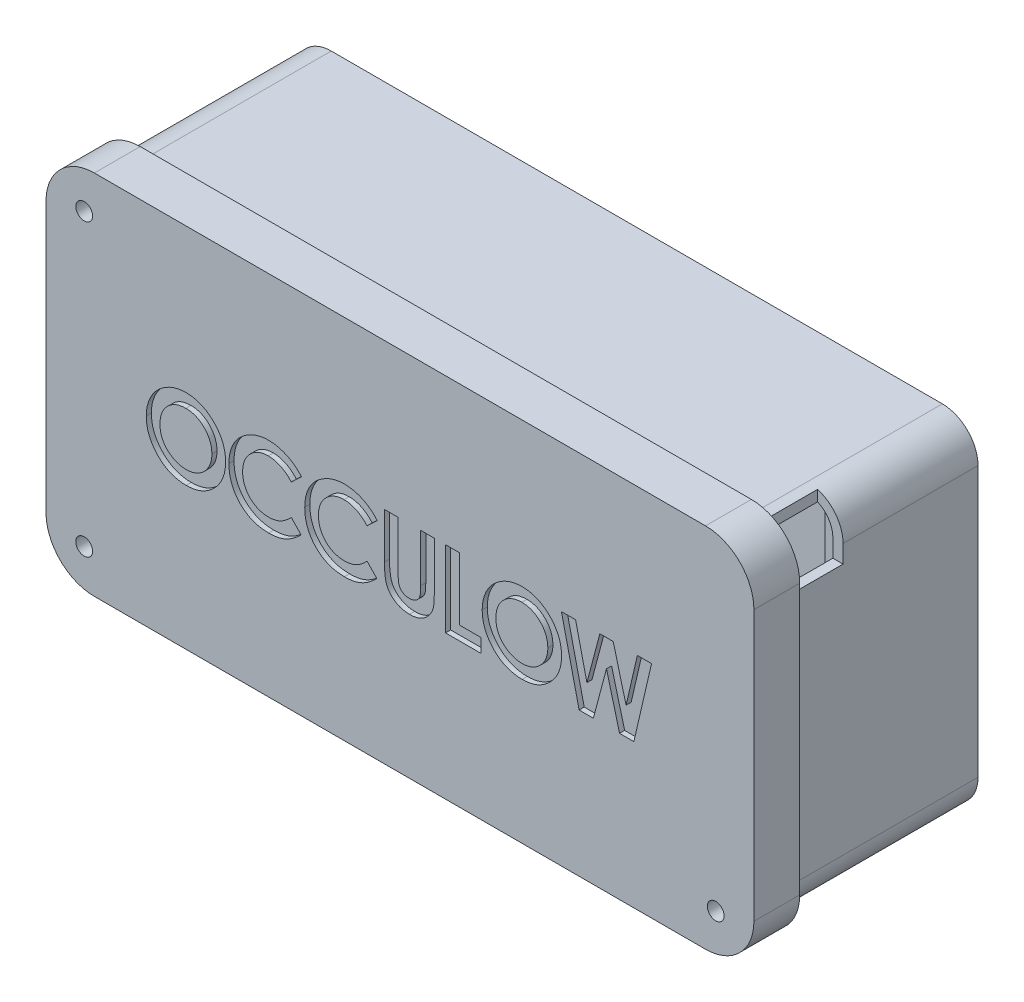
from build123d import *

# Parameters (mm, degrees)
SKETCH1_W            = 130
SKETCH1_H            = 40
SKETCH1_R            = 5.5
SKETCH1_W_2          = 10
SKETCH1_H_2          = 7
BOSS_EXTRUDE1_DEPTH  = 2
SKETCH2_W            = 130
SKETCH2_H            = 65
SKETCH2_R            = 1
BOSS_EXTRUDE2_DEPTH  = 3.5
SKETCH4_R            = 3.5
SKETCH4_R_2          = 1
BOSS_EXTRUDE3_DEPTH  = 2.5
SKETCH5_W            = 43.5
SKETCH5_H            = 65
BOSS_EXTRUDE4_DEPTH  = 2
SKETCH6_W            = 6.5
SKETCH6_H            = 6.5
BOSS_EXTRUDE5_DEPTH  = 40
SKETCH7_W            = 43.5
SKETCH7_H            = 65
BOSS_EXTRUDE6_DEPTH  = 2
SKETCH8_W            = 134
SKETCH8_H            = 43.5
BOSS_EXTRUDE7_DEPTH  = 2
SKETCH12_W           = 9.5
SKETCH12_H           = 63
BOSS_EXTRUDE10_DEPTH = 15
SKETCH9_W            = 5
SKETCH9_H            = 10.5
CUT_EXTRUDE1_DEPTH   = 17
BOSS_EXTRUDE8_DEPTH  = 18
BOSS_EXTRUDE9_DEPTH  = 40
SKETCH13_R           = 1
CUT_EXTRUDE2_DEPTH   = 25
FILLET1_R            = 5
FILLET2_R            = 7
FILLET3_R            = 1
BOSS_EXTRUDE11_DEPTH = 6
SKETCH15_R           = 1.65
BOSS_EXTRUDE12_DEPTH = 3
CUT_EXTRUDE3_DEPTH   = 1


with BuildPart() as part:
    # Sketch1 → Boss-Extrude1 (new body)
    with BuildSketch(Plane(origin=(0, 0, 0), x_dir=(1, 0, 0), z_dir=(0, 1, 0))):
        with Locations((0, 7.5)):
            Rectangle(SKETCH1_W, SKETCH1_H)
        with Locations((0, 15)):
            Circle(SKETCH1_R, mode=Mode.SUBTRACT)
        Rectangle(SKETCH1_W_2, SKETCH1_H_2, mode=Mode.SUBTRACT)
    extrude(amount=-BOSS_EXTRUDE1_DEPTH)

    # Sketch2 → Boss-Extrude2 (add)
    with BuildSketch(Plane(origin=(0, 0, -27.5), x_dir=(-1, 0, 0), z_dir=(0, 0, -1))):
        with Locations((0, 30.5)):
            Rectangle(SKETCH2_W, SKETCH2_H)
        with Locations((-15, 56)):
            Circle(SKETCH2_R, mode=Mode.SUBTRACT)
        with Locations((-45, 56)):
            Circle(SKETCH2_R, mode=Mode.SUBTRACT)
        with Locations((-45, 14)):
            Circle(SKETCH2_R, mode=Mode.SUBTRACT)
        with Locations((-15, 14)):
            Circle(SKETCH2_R, mode=Mode.SUBTRACT)
        with Locations((35, 45.5)):
            Circle(SKETCH2_R, mode=Mode.SUBTRACT)
        with Locations((35, 15.5)):
            Circle(SKETCH2_R, mode=Mode.SUBTRACT)
    extrude(amount=BOSS_EXTRUDE2_DEPTH)

    # Sketch4 → Boss-Extrude3 (add)
    with BuildSketch(Plane.XY.offset(-27.5)):
        with Locations((15, 56)):
            Circle(SKETCH4_R)
        with Locations((15, 56)):
            Circle(SKETCH4_R_2, mode=Mode.SUBTRACT)
        with Locations((45, 56)):
            Circle(SKETCH4_R)
        with Locations((45, 56)):
            Circle(SKETCH4_R_2, mode=Mode.SUBTRACT)
        with Locations((15, 14)):
            Circle(SKETCH4_R)
        with Locations((15, 14)):
            Circle(SKETCH4_R_2, mode=Mode.SUBTRACT)
        with Locations((45, 14)):
            Circle(SKETCH4_R)
        with Locations((45, 14)):
            Circle(SKETCH4_R_2, mode=Mode.SUBTRACT)
    extrude(amount=BOSS_EXTRUDE3_DEPTH)

    # Sketch5 → Boss-Extrude4 (add)
    with BuildSketch(Plane(origin=(65, 0, 0), x_dir=(0, 0, -1), z_dir=(1, 0, 0))):
        with Locations((9.25, 30.5)):
            Rectangle(SKETCH5_W, SKETCH5_H)
    extrude(amount=BOSS_EXTRUDE4_DEPTH)

    # Sketch6 → Boss-Extrude5 (add)
    with BuildSketch(Plane.XY.offset(12.5)):
        Polygon((55.5, 9), (55.5, 0), (65, 0), (65, 12), (58.5, 12), (58.5, 14), (55.5, 14), align=None)
        with Locations((-61.75, 59.75)):
            Rectangle(SKETCH6_W, SKETCH6_H)
        with Locations((-61.75, 3.25)):
            Rectangle(SKETCH6_W, SKETCH6_H)
    extrude(amount=-BOSS_EXTRUDE5_DEPTH)

    # Sketch7 → Boss-Extrude6 (add)
    with BuildSketch(Plane.ZY.offset(65)):
        with Locations((-9.25, 30.5)):
            Rectangle(SKETCH7_W, SKETCH7_H)
    extrude(amount=BOSS_EXTRUDE6_DEPTH)

    # Sketch8 → Boss-Extrude7 (add)
    with BuildSketch(Plane(origin=(0, 63, 0), x_dir=(1, 0, 0), z_dir=(0, 1, 0))):
        with Locations((0, 9.25)):
            Rectangle(SKETCH8_W, SKETCH8_H)
    extrude(amount=BOSS_EXTRUDE7_DEPTH)

    # Sketch12 → Boss-Extrude10 (add)
    with BuildSketch(Plane.XY.offset(-27.5)):
        with Locations((60.25, 31.5)):
            Rectangle(SKETCH12_W, SKETCH12_H)
    extrude(amount=BOSS_EXTRUDE10_DEPTH)

    # Sketch9 → Cut-Extrude1 (cut)
    with BuildSketch(Plane.XY.offset(12.5)):
        with Locations((64.5, 59.75)):
            Rectangle(SKETCH9_W, SKETCH9_H)
    extrude(amount=-CUT_EXTRUDE1_DEPTH, mode=Mode.SUBTRACT)

    # Sketch10 → Boss-Extrude8 (add)
    with BuildSketch(Plane.XY.offset(-27.5)):
        Polygon((-14.75, 0), (-6.75, 8), (-4.7, 5), (-6.75, 5), (-6.75, 0), align=None)
        Polygon((4.7, 5), (6.75, 5), (6.75, 0), (14.75, 0), (6.75, 8), align=None)
    extrude(amount=BOSS_EXTRUDE8_DEPTH)

    # Sketch11 → Boss-Extrude9 (add)
    with BuildSketch(Plane.XY.offset(-27.5)):
        Polygon((-21, 0), (-21, 5), (-18.25, 5), (-21, 8), (-29, 0), align=None)
        Polygon((29, 0), (21, 0), (21, 5), (18.25, 5), (21, 8), align=None)
    extrude(amount=BOSS_EXTRUDE9_DEPTH)

    # Sketch13 → Cut-Extrude2 (cut)
    with BuildSketch(Plane.XY.offset(12.5)):
        with Locations((-62, 60)):
            Circle(SKETCH13_R)
        with Locations((-62, 3)):
            Circle(SKETCH13_R)
        with Locations((62, 3)):
            Circle(SKETCH13_R)
    extrude(amount=-CUT_EXTRUDE2_DEPTH, mode=Mode.SUBTRACT)

    # Fillet1
    fillet1_edges = [part.edges().sort_by_distance(p)[0] for p in [
        (65, 63, -8.5),
        (-65, 56.5, -7.5),
        (-58.5, 63, -7.5),
        (55.5, 0, -7.5),
        (-58.5, 0, -7.5),
        (-65, 6.5, -7.5),
        (55.5, 63, -20),
        (14.75, 0, -18.5),
        (-14.75, 0, -18.5),
        (29, 0, -7.5),
        (-29, 0, -7.5),
    ]]
    fillet(fillet1_edges, radius=FILLET1_R)

    # Fillet2
    fillet2_edges = [part.edges().sort_by_distance(p)[0] for p in [
        (67, 65, -17.75),
        (67, -2, -9.25),
        (-67, 65, -9.25),
        (-58.5, 56.5, -7.5),
        (-58.5, 6.5, -7.5),
        (-67, -2, -9.25),
    ]]
    fillet(fillet2_edges, radius=FILLET2_R)

    # Fillet3
    fillet3_edges = [part.edges().sort_by_distance(p)[0] for p in [
        (-6.75, 8, -18.5),
        (6.75, 8, -18.5),
        (-21, 8, -7.5),
        (21, 8, -7.5),
    ]]
    fillet(fillet3_edges, radius=FILLET3_R)


with BuildPart() as body_2:
    # Sketch14 → Boss-Extrude11 (new body)
    with BuildSketch(Plane.XY.offset(12.5)):
        with BuildLine():
            Line((60, 67.5), (-60, 67.5))
            ThreePointArc((-60, 67.5), (-66.717514421, 64.717514421), (-69.5, 58))
            Line((-69.5, 58), (-69.5, 5))
            ThreePointArc((-69.5, 5), (-66.717514421, -1.717514421), (-60, -4.5))
            Line((-60, -4.5), (60, -4.5))
            ThreePointArc((60, -4.5), (66.717514421, -1.717514421), (69.5, 5))
            Line((69.5, 5), (69.5, 58))
            ThreePointArc((69.5, 58), (66.717514421, 64.717514421), (60, 67.5))
        make_face()
        with BuildLine():
            Line((60, 65.5), (-60, 65.5))
            ThreePointArc((-60, 65.5), (-65.303300859, 63.303300859), (-67.5, 58))
            Line((-67.5, 58), (-67.5, 5))
            ThreePointArc((-67.5, 5), (-65.303300859, -0.303300859), (-60, -2.5))
            Line((-60, -2.5), (60, -2.5))
            ThreePointArc((60, -2.5), (65.303300859, -0.303300859), (67.5, 5))
            Line((67.5, 5), (67.5, 58))
            ThreePointArc((67.5, 58), (65.303300859, 63.303300859), (60, 65.5))
        make_face(mode=Mode.SUBTRACT)
    extrude(amount=-BOSS_EXTRUDE11_DEPTH)

    # Sketch15 → Boss-Extrude12 (add)
    with BuildSketch(Plane.XY.offset(12.5)):
        with BuildLine():
            Line((60, 67.5), (-60, 67.5))
            ThreePointArc((-60, 67.5), (-66.717514421, 64.717514421), (-69.5, 58))
            Line((-69.5, 58), (-69.5, 5))
            ThreePointArc((-69.5, 5), (-66.717514421, -1.717514421), (-60, -4.5))
            Line((-60, -4.5), (60, -4.5))
            ThreePointArc((60, -4.5), (66.717514421, -1.717514421), (69.5, 5))
            Line((69.5, 5), (69.5, 58))
            ThreePointArc((69.5, 58), (66.717514421, 64.717514421), (60, 67.5))
        make_face()
        with Locations((62, 3)):
            Circle(SKETCH15_R, mode=Mode.SUBTRACT)
        with Locations((-62, 3)):
            Circle(SKETCH15_R, mode=Mode.SUBTRACT)
        with Locations((-62, 60)):
            Circle(SKETCH15_R, mode=Mode.SUBTRACT)
    extrude(amount=BOSS_EXTRUDE12_DEPTH)

    # Sketch16 → Cut-Extrude3 (cut)
    with BuildSketch(Plane.XY.offset(15.5)):
        with BuildLine():
            add(Edge.make_bspline(
                [(-41.995066722, 39.162258162), (-41.734273339, 39.155505754), (-41.219408132, 39.142174972), (-40.462227207, 39.031052498), (-39.732543384, 38.849994357), (-39.030686623, 38.598310446), (-38.358414294, 38.269183885), (-37.713355065, 37.871945627), (-37.09781951, 37.39909804), (-36.518115143, 36.861671876), (-35.982363756, 36.27724439), (-35.518134866, 35.648004298), (-35.122257499, 34.990255843), (-34.794153279, 34.302236569), (-34.544240845, 33.579181614), (-34.368866952, 32.824777604), (-34.256197915, 32.039239158), (-34.243239243, 31.504394547), (-34.236653261, 31.232570662)],
                knots=[0, 0, 0, 0, 0.000782082, 0.001544006, 0.00229027, 0.003034499, 0.003776315, 0.004531831, 0.0053035, 0.006100907, 0.006900716, 0.007678376, 0.008442596, 0.009200665, 0.009960888, 0.010732725, 0.011521429, 0.01233653, 0.01233653, 0.01233653, 0.01233653], degree=3))
            add(Edge.make_bspline(
                [(-34.236653261, 31.232570662), (-34.243667046, 30.963809604), (-34.257487936, 30.434207317), (-34.364267309, 29.655907918), (-34.54259452, 28.909585146), (-34.788268243, 28.193549683), (-35.110421893, 27.51126976), (-35.49857922, 26.858389113), (-35.962982957, 26.240966633), (-36.486694477, 25.65933365), (-37.06325541, 25.131376913), (-37.673924967, 24.66611595), (-38.315883451, 24.271871368), (-38.988191242, 23.94882375), (-39.69229007, 23.69811839), (-40.426440725, 23.521227542), (-41.190597779, 23.413727402), (-41.710261633, 23.399996789), (-41.974033069, 23.393027393)],
                knots=[0, 0, 0, 0, 0.000806095, 0.001588437, 0.002351504, 0.003105064, 0.003855135, 0.004611112, 0.005379744, 0.006169048, 0.006955929, 0.007721565, 0.008468815, 0.009212029, 0.009955244, 0.010706626, 0.011474083, 0.012265169, 0.012265169, 0.012265169, 0.012265169], degree=3))
            add(Edge.make_bspline(
                [(-41.974033069, 23.393027393), (-42.249906363, 23.399279285), (-42.791959677, 23.411563398), (-43.585257129, 23.52837971), (-44.345304634, 23.704345882), (-45.065717357, 23.966965953), (-45.753832085, 24.295263126), (-46.404593036, 24.699580777), (-47.017781512, 25.179250739), (-47.589880165, 25.721988488), (-48.10820293, 26.315862626), (-48.565724439, 26.943237988), (-48.951653981, 27.599321979), (-49.266005677, 28.284421659), (-49.513827926, 28.994279302), (-49.688638366, 29.733218144), (-49.791903064, 30.499465943), (-49.806287236, 31.019916765), (-49.813576338, 31.283652393)],
                knots=[0, 0, 0, 0, 0.000827108, 0.001625155, 0.002400611, 0.003163838, 0.003920489, 0.004684278, 0.005457238, 0.006252167, 0.007046466, 0.007818795, 0.008578411, 0.00932595, 0.010076671, 0.010830273, 0.011600302, 0.012391388, 0.012391388, 0.012391388, 0.012391388], degree=3))
            add(Edge.make_bspline(
                [(-49.813576338, 31.283652393), (-49.811288598, 31.461079916), (-49.806742086, 31.813688324), (-49.751974561, 32.336235986), (-49.673125072, 32.848584218), (-49.556510419, 33.348690282), (-49.414853421, 33.840082193), (-49.231316769, 34.318185954), (-49.02240239, 34.788109027), (-48.778305608, 35.244301033), (-48.506893588, 35.682564623), (-48.21075891, 36.100832433), (-47.889156948, 36.494046992), (-47.543123686, 36.864792345), (-47.171466649, 37.210631556), (-46.779074601, 37.53646046), (-46.358337419, 37.833623884), (-45.918463723, 38.109379149), (-45.461933417, 38.358739854), (-44.990604994, 38.570988228), (-44.514188752, 38.756341118), (-44.026320412, 38.902629814), (-43.53222835, 39.021780427), (-43.026634194, 39.100576772), (-42.5141057, 39.15534278), (-42.168490309, 39.159947564), (-41.995066722, 39.162258162)],
                knots=[0, 0, 0, 0, 0.000532063, 0.001057389, 0.001574609, 0.002086309, 0.002596888, 0.003107537, 0.003621315, 0.004138849, 0.004658342, 0.005166928, 0.005675176, 0.006181145, 0.006687113, 0.007197268, 0.007710043, 0.008231124, 0.00875415, 0.009269166, 0.009780884, 0.010286567, 0.010796022, 0.011304341, 0.011820696, 0.012340744, 0.012340744, 0.012340744, 0.012340744], degree=3))
        make_face()
        with BuildLine():
            add(Edge.make_bspline(
                [(-42.03713403, 36.46995047), (-42.212647943, 36.465241037), (-42.559042172, 36.455946502), (-43.067139422, 36.385134718), (-43.554930726, 36.272040248), (-44.019712063, 36.108224291), (-44.463497836, 35.899728155), (-44.88707474, 35.64728035), (-45.28457711, 35.342203265), (-45.661305257, 35.000875129), (-46.001617146, 34.620557143), (-46.302293436, 34.212981742), (-46.553911061, 33.778829569), (-46.764642398, 33.322133795), (-46.923276391, 32.837758998), (-47.036266628, 32.329499337), (-47.107672239, 31.796479056), (-47.116673006, 31.433119824), (-47.121268646, 31.2475947)],
                knots=[0, 0, 0, 0, 0.000526391, 0.001038884, 0.001535951, 0.002026315, 0.002514261, 0.003004845, 0.003502447, 0.004015038, 0.00452784, 0.005030874, 0.005531803, 0.006030656, 0.006537115, 0.007057606, 0.007590949, 0.008147358, 0.008147358, 0.008147358, 0.008147358], degree=3))
            add(Edge.make_bspline(
                [(-47.121268646, 31.2475947), (-47.115175528, 31.04199113), (-47.103234029, 30.6390422), (-47.019212183, 30.051231156), (-46.875459168, 29.496101966), (-46.66788261, 28.976369682), (-46.41043322, 28.486263068), (-46.090721938, 28.031789076), (-45.713926572, 27.610226529), (-45.423646474, 27.364100755), (-45.276316722, 27.239181239)],
                knots=[0, 0, 0, 0, 0.000616718, 0.001208665, 0.001777146, 0.002332897, 0.002884015, 0.003434191, 0.003995905, 0.004574828, 0.004574828, 0.004574828, 0.004574828], degree=3))
            add(Edge.make_bspline(
                [(-45.276316722, 27.239181239), (-45.155625529, 27.146895498), (-44.916962335, 26.964403231), (-44.536003915, 26.730501953), (-44.143691758, 26.530025224), (-43.737065375, 26.368042399), (-43.316983541, 26.240629432), (-42.883503861, 26.151404226), (-42.43724054, 26.095407692), (-42.135456368, 26.088715046), (-41.983047492, 26.085335085)],
                knots=[0, 0, 0, 0, 0.000455543, 0.000900823, 0.001338907, 0.001775804, 0.002212123, 0.002654105, 0.003102094, 0.00355918, 0.00355918, 0.00355918, 0.00355918], degree=3))
            add(Edge.make_bspline(
                [(-41.983047492, 26.085335085), (-41.810551545, 26.090084448), (-41.471160345, 26.099428969), (-40.9725216, 26.169369022), (-40.494810537, 26.287732844), (-40.035061486, 26.450111749), (-39.594600157, 26.661225735), (-39.175579205, 26.921503679), (-38.777263973, 27.227749703), (-38.401015773, 27.573560225), (-38.057107133, 27.955376401), (-37.757058292, 28.365125768), (-37.497440484, 28.79378032), (-37.291091307, 29.247407014), (-37.126190044, 29.721723826), (-37.014559704, 30.218831402), (-36.942550877, 30.736680476), (-36.933547575, 31.089095072), (-36.928960953, 31.268628354)],
                knots=[0, 0, 0, 0, 0.000517386, 0.001017973, 0.001506981, 0.001991678, 0.002478197, 0.002969343, 0.003468766, 0.003983387, 0.004500432, 0.005007666, 0.00550495, 0.006001071, 0.006499951, 0.007008723, 0.007527172, 0.008065569, 0.008065569, 0.008065569, 0.008065569], degree=3))
            add(Edge.make_bspline(
                [(-36.928960953, 31.268628354), (-36.933706273, 31.447129271), (-36.94304671, 31.798481102), (-37.013109861, 32.314998791), (-37.13072305, 32.809911782), (-37.293589562, 33.284028323), (-37.501561474, 33.737813223), (-37.75873984, 34.169670706), (-38.064222255, 34.579183272), (-38.41097806, 34.963560249), (-38.788400441, 35.316778069), (-39.193601078, 35.623306929), (-39.615242004, 35.889670762), (-40.062997718, 36.098329433), (-40.527707512, 36.264567353), (-41.012207072, 36.386987343), (-41.518331467, 36.455449046), (-41.862658359, 36.465073575), (-42.03713403, 36.46995047)],
                knots=[0, 0, 0, 0, 0.000535396, 0.001053845, 0.001560375, 0.002059255, 0.002555376, 0.003055241, 0.003564261, 0.00408555, 0.004606457, 0.00511248, 0.005607763, 0.006099708, 0.006591074, 0.00708664, 0.007596156, 0.008119545, 0.008119545, 0.008119545, 0.008119545], degree=3))
        make_face(mode=Mode.SUBTRACT)
        with BuildLine():
            Line((-19.352037876, 36.175479316), (-21.32619653, 34.288460085))
            add(Edge.make_bspline(
                [(-21.32619653, 34.288460085), (-21.49366075, 34.461618369), (-21.820770837, 34.799850747), (-22.347868287, 35.247640608), (-22.896030443, 35.620812869), (-23.454593904, 35.935096171), (-24.033605609, 36.172873888), (-24.626370605, 36.346146516), (-25.23667387, 36.451784288), (-25.649703646, 36.463871118), (-25.85744653, 36.46995047)],
                knots=[0, 0, 0, 0, 0.000722405, 0.001411083, 0.002070342, 0.002709208, 0.003330281, 0.003943623, 0.004559132, 0.005182004, 0.005182004, 0.005182004, 0.005182004], degree=3))
            add(Edge.make_bspline(
                [(-25.85744653, 36.46995047), (-26.030937084, 36.46514757), (-26.373301577, 36.455669576), (-26.87598237, 36.386186532), (-27.356822527, 36.268027593), (-27.817468041, 36.105182687), (-28.256563442, 35.894470021), (-28.675029349, 35.636052683), (-29.071834051, 35.332264547), (-29.441735988, 34.984677428), (-29.78010928, 34.604912381), (-30.079083629, 34.199703981), (-30.329522605, 33.769980539), (-30.535053799, 33.320093977), (-30.695154653, 32.847961999), (-30.809486779, 32.353902461), (-30.875613424, 31.837326978), (-30.885483269, 31.486162813), (-30.890499415, 31.307690854)],
                knots=[0, 0, 0, 0, 0.000520387, 0.001026927, 0.001518853, 0.00200355, 0.00249007, 0.00297708, 0.003476502, 0.003986718, 0.004497518, 0.005000552, 0.005494777, 0.005986914, 0.006481978, 0.006987822, 0.00750588, 0.008041275, 0.008041275, 0.008041275, 0.008041275], degree=3))
            add(Edge.make_bspline(
                [(-30.890499415, 31.307690854), (-30.889053819, 31.182426746), (-30.88620452, 30.935528616), (-30.8550139, 30.570297757), (-30.804789647, 30.215937478), (-30.73210271, 29.872984543), (-30.64120698, 29.541141744), (-30.534565592, 29.21754629), (-30.40078554, 28.906669542), (-30.252287664, 28.604900869), (-30.079586345, 28.320474406), (-29.893382465, 28.049250169), (-29.691474757, 27.792557671), (-29.472555454, 27.551446279), (-29.233543539, 27.329684024), (-28.980616586, 27.120602251), (-28.709508067, 26.929434986), (-28.425849593, 26.751384676), (-28.127190713, 26.596710856), (-27.821634735, 26.456606257), (-27.504548815, 26.342820493), (-27.179793664, 26.251098786), (-26.848529843, 26.173103172), (-26.507517283, 26.125078876), (-26.159712137, 26.088710639), (-25.924654237, 26.086465113), (-25.806364799, 26.085335085)],
                knots=[0, 0, 0, 0, 0.000375709, 0.00074053, 0.001098758, 0.001448815, 0.001791416, 0.00213064, 0.002469957, 0.002805905, 0.003138802, 0.003467193, 0.003792407, 0.004117829, 0.004443085, 0.004769726, 0.005101563, 0.005437592, 0.005773606, 0.006109823, 0.006445354, 0.006782977, 0.007121935, 0.007465299, 0.00781542, 0.008170102, 0.008170102, 0.008170102, 0.008170102], degree=3))
            add(Edge.make_bspline(
                [(-25.806364799, 26.085335085), (-25.605725584, 26.091138636), (-25.2115217, 26.102541104), (-24.632970818, 26.191706791), (-24.081669466, 26.338379301), (-23.641182323, 26.511591012), (-23.296072282, 26.682639826), (-23.03334511, 26.840851555), (-22.761664736, 27.017828745), (-22.485543541, 27.220250707), (-22.201875708, 27.445688295), (-21.915668628, 27.699079013), (-21.61959535, 27.972079069), (-21.42564068, 28.166924573), (-21.32619653, 28.26682547)],
                knots=[0, 0, 0, 0, 0.000601712, 0.001182208, 0.001751459, 0.002310005, 0.00259892, 0.002906058, 0.003229421, 0.003571402, 0.003932742, 0.00431604, 0.004717887, 0.005140712, 0.005140712, 0.005140712, 0.005140712], degree=3))
            Line((-21.32619653, 28.26682547), (-19.41213403, 26.256609123))
            add(Edge.make_bspline(
                [(-19.41213403, 26.256609123), (-19.546682321, 26.126706972), (-19.809291812, 25.873165754), (-20.205430937, 25.513160883), (-20.601071506, 25.189656486), (-20.986655667, 24.890910772), (-21.368499689, 24.625626928), (-21.746563079, 24.393540013), (-22.116565995, 24.188780213), (-22.486191665, 24.014800701), (-22.857740091, 23.867074026), (-23.240019759, 23.739891055), (-23.634199332, 23.632298837), (-24.042686282, 23.545486047), (-24.461670489, 23.47587391), (-24.89507309, 23.428886119), (-25.340146097, 23.397297791), (-25.642046014, 23.394459318), (-25.794345569, 23.393027393)],
                knots=[0, 0, 0, 0, 0.000561071, 0.00109509, 0.001605244, 0.002093856, 0.002558126, 0.00299927, 0.003424214, 0.003826117, 0.004223957, 0.004623042, 0.005034163, 0.005449066, 0.005875378, 0.006307747, 0.006756471, 0.00721329, 0.00721329, 0.00721329, 0.00721329], degree=3))
            add(Edge.make_bspline(
                [(-25.794345569, 23.393027393), (-26.074100986, 23.400158916), (-26.621504574, 23.414113325), (-27.423710259, 23.517506049), (-28.185784127, 23.690842129), (-28.909580159, 23.935987156), (-29.594868206, 24.249148439), (-30.24147295, 24.633069467), (-30.848352208, 25.086730223), (-31.41060359, 25.604813361), (-31.919186723, 26.176992695), (-32.368715316, 26.791356327), (-32.740565385, 27.450923631), (-33.04932051, 28.14595069), (-33.290762957, 28.879609182), (-33.460697509, 29.652692702), (-33.565494907, 30.464454791), (-33.576959891, 31.01890701), (-33.582807107, 31.301681239)],
                knots=[0, 0, 0, 0, 0.000839116, 0.001641918, 0.002421855, 0.003180127, 0.003930397, 0.004678135, 0.005431743, 0.006199429, 0.006967749, 0.007725056, 0.008478658, 0.009234676, 0.010003396, 0.010791464, 0.011606188, 0.012454188, 0.012454188, 0.012454188, 0.012454188], degree=3))
            add(Edge.make_bspline(
                [(-33.582807107, 31.301681239), (-33.580336357, 31.486104178), (-33.575439934, 31.85158537), (-33.523978074, 32.389968775), (-33.452237248, 32.914796293), (-33.338426952, 33.420618475), (-33.201239865, 33.914249679), (-33.030629698, 34.390324709), (-32.826868939, 34.850211855), (-32.596525277, 35.294680994), (-32.335939797, 35.720820377), (-32.044837209, 36.124968795), (-31.730711628, 36.5102462), (-31.386015129, 36.871541172), (-31.015756604, 37.212025951), (-30.618264377, 37.529855384), (-30.195929166, 37.829587504), (-29.747607866, 38.103492948), (-29.282010166, 38.351254981), (-28.805008478, 38.569791675), (-28.31777474, 38.752438026), (-27.82236902, 38.903936437), (-27.316698236, 39.017019289), (-26.804371736, 39.102619359), (-26.281030237, 39.150470346), (-25.929651759, 39.158303858), (-25.752278261, 39.162258162)],
                knots=[0, 0, 0, 0, 0.000553089, 0.001096087, 0.001621318, 0.002141159, 0.002650072, 0.003157609, 0.003656742, 0.004158041, 0.004658438, 0.005153749, 0.005651214, 0.006148562, 0.006650446, 0.007159138, 0.007674364, 0.008203108, 0.008734075, 0.009255805, 0.00977595, 0.010294007, 0.010808636, 0.011329301, 0.011851351, 0.012383508, 0.012383508, 0.012383508, 0.012383508], degree=3))
            add(Edge.make_bspline(
                [(-25.752278261, 39.162258162), (-25.60096048, 39.159991456), (-25.299898202, 39.155481612), (-24.851565949, 39.117887153), (-24.406819248, 39.058845435), (-23.967250427, 38.969764056), (-23.529715243, 38.864013202), (-23.099963396, 38.725547046), (-22.67121532, 38.571200421), (-22.250195292, 38.386710546), (-21.836315628, 38.185323183), (-21.439272112, 37.956841906), (-21.052398421, 37.715327198), (-20.684267442, 37.446485161), (-20.32798329, 37.160067193), (-19.985409006, 36.854736996), (-19.65955088, 36.525403819), (-19.455060413, 36.292710488), (-19.352037876, 36.175479316)],
                knots=[0, 0, 0, 0, 0.000453885, 0.000903051, 0.001348827, 0.001799047, 0.002247972, 0.002698433, 0.003152825, 0.003614452, 0.004076724, 0.00453291, 0.004988067, 0.005444264, 0.00589946, 0.006359107, 0.006820176, 0.007288309, 0.007288309, 0.007288309, 0.007288309], degree=3))
        make_face()
        with BuildLine():
            Line((-4.467422492, 36.175479316), (-6.441581146, 34.288460085))
            add(Edge.make_bspline(
                [(-6.441581146, 34.288460085), (-6.609045366, 34.461618369), (-6.936155452, 34.799850747), (-7.463252902, 35.247640608), (-8.011415058, 35.620812869), (-8.56997852, 35.935096171), (-9.148990224, 36.172873888), (-9.74175522, 36.346146516), (-10.352058486, 36.451784288), (-10.765088261, 36.463871118), (-10.972831146, 36.46995047)],
                knots=[0, 0, 0, 0, 0.000722405, 0.001411083, 0.002070342, 0.002709208, 0.003330281, 0.003943623, 0.004559132, 0.005182004, 0.005182004, 0.005182004, 0.005182004], degree=3))
            add(Edge.make_bspline(
                [(-10.972831146, 36.46995047), (-11.146321699, 36.46514757), (-11.488686193, 36.455669576), (-11.991366985, 36.386186532), (-12.472207143, 36.268027593), (-12.932852656, 36.105182687), (-13.371948058, 35.894470021), (-13.790413965, 35.636052683), (-14.187218667, 35.332264547), (-14.557120603, 34.984677428), (-14.895493896, 34.604912381), (-15.194468245, 34.199703981), (-15.44490722, 33.769980539), (-15.650438414, 33.320093977), (-15.810539269, 32.847961999), (-15.924871394, 32.353902461), (-15.99099804, 31.837326978), (-16.000867885, 31.486162813), (-16.00588403, 31.307690854)],
                knots=[0, 0, 0, 0, 0.000520387, 0.001026927, 0.001518853, 0.00200355, 0.00249007, 0.00297708, 0.003476502, 0.003986718, 0.004497518, 0.005000552, 0.005494777, 0.005986914, 0.006481978, 0.006987822, 0.00750588, 0.008041275, 0.008041275, 0.008041275, 0.008041275], degree=3))
            add(Edge.make_bspline(
                [(-16.00588403, 31.307690854), (-16.004438434, 31.182426746), (-16.001589135, 30.935528616), (-15.970398515, 30.570297757), (-15.920174262, 30.215937478), (-15.847487325, 29.872984543), (-15.756591595, 29.541141744), (-15.649950208, 29.21754629), (-15.516170156, 28.906669542), (-15.36767228, 28.604900869), (-15.194970961, 28.320474406), (-15.00876708, 28.049250169), (-14.806859372, 27.792557671), (-14.587940069, 27.551446279), (-14.348928154, 27.329684024), (-14.096001201, 27.120602251), (-13.824892682, 26.929434986), (-13.541234208, 26.751384676), (-13.242575328, 26.596710856), (-12.93701935, 26.456606257), (-12.61993343, 26.342820493), (-12.295178279, 26.251098786), (-11.963914458, 26.173103172), (-11.622901898, 26.125078876), (-11.275096753, 26.088710639), (-11.040038853, 26.086465113), (-10.921749415, 26.085335085)],
                knots=[0, 0, 0, 0, 0.000375709, 0.00074053, 0.001098758, 0.001448815, 0.001791416, 0.00213064, 0.002469957, 0.002805905, 0.003138802, 0.003467193, 0.003792407, 0.004117829, 0.004443085, 0.004769726, 0.005101563, 0.005437592, 0.005773606, 0.006109823, 0.006445354, 0.006782977, 0.007121935, 0.007465299, 0.00781542, 0.008170102, 0.008170102, 0.008170102, 0.008170102], degree=3))
            add(Edge.make_bspline(
                [(-10.921749415, 26.085335085), (-10.721110199, 26.091138636), (-10.326906315, 26.102541104), (-9.748355433, 26.191706791), (-9.197054081, 26.338379301), (-8.756566939, 26.511591012), (-8.411456897, 26.682639826), (-8.148729725, 26.840851555), (-7.877049352, 27.017828745), (-7.600928156, 27.220250707), (-7.317260323, 27.445688295), (-7.031053243, 27.699079013), (-6.734979965, 27.972079069), (-6.541025296, 28.166924573), (-6.441581146, 28.26682547)],
                knots=[0, 0, 0, 0, 0.000601712, 0.001182208, 0.001751459, 0.002310005, 0.00259892, 0.002906058, 0.003229421, 0.003571402, 0.003932742, 0.00431604, 0.004717887, 0.005140712, 0.005140712, 0.005140712, 0.005140712], degree=3))
            Line((-6.441581146, 28.26682547), (-4.527518646, 26.256609123))
            add(Edge.make_bspline(
                [(-4.527518646, 26.256609123), (-4.662066937, 26.126706972), (-4.924676427, 25.873165754), (-5.320815553, 25.513160883), (-5.716456122, 25.189656486), (-6.102040282, 24.890910772), (-6.483884304, 24.625626928), (-6.861947695, 24.393540013), (-7.231950611, 24.188780213), (-7.601576281, 24.014800701), (-7.973124707, 23.867074026), (-8.355404374, 23.739891055), (-8.749583948, 23.632298837), (-9.158070897, 23.545486047), (-9.577055104, 23.47587391), (-10.010457705, 23.428886119), (-10.455530713, 23.397297791), (-10.757430629, 23.394459318), (-10.909730184, 23.393027393)],
                knots=[0, 0, 0, 0, 0.000561071, 0.00109509, 0.001605244, 0.002093856, 0.002558126, 0.00299927, 0.003424214, 0.003826117, 0.004223957, 0.004623042, 0.005034163, 0.005449066, 0.005875378, 0.006307747, 0.006756471, 0.00721329, 0.00721329, 0.00721329, 0.00721329], degree=3))
            add(Edge.make_bspline(
                [(-10.909730184, 23.393027393), (-11.189485601, 23.400158916), (-11.736889189, 23.414113325), (-12.539094875, 23.517506049), (-13.301168742, 23.690842129), (-14.024964775, 23.935987156), (-14.710252821, 24.249148439), (-15.356857565, 24.633069467), (-15.963736823, 25.086730223), (-16.525988205, 25.604813361), (-17.034571338, 26.176992695), (-17.484099932, 26.791356327), (-17.855950001, 27.450923631), (-18.164705126, 28.14595069), (-18.406147573, 28.879609182), (-18.576082124, 29.652692702), (-18.680879522, 30.464454791), (-18.692344506, 31.01890701), (-18.698191722, 31.301681239)],
                knots=[0, 0, 0, 0, 0.000839116, 0.001641918, 0.002421855, 0.003180127, 0.003930397, 0.004678135, 0.005431743, 0.006199429, 0.006967749, 0.007725056, 0.008478658, 0.009234676, 0.010003396, 0.010791464, 0.011606188, 0.012454188, 0.012454188, 0.012454188, 0.012454188], degree=3))
            add(Edge.make_bspline(
                [(-18.698191722, 31.301681239), (-18.695720972, 31.486104178), (-18.690824549, 31.85158537), (-18.639362689, 32.389968775), (-18.567621864, 32.914796293), (-18.453811567, 33.420618475), (-18.31662448, 33.914249679), (-18.146014313, 34.390324709), (-17.942253554, 34.850211855), (-17.711909893, 35.294680994), (-17.451324412, 35.720820377), (-17.160221824, 36.124968795), (-16.846096243, 36.5102462), (-16.501399744, 36.871541172), (-16.131141219, 37.212025951), (-15.733648992, 37.529855384), (-15.311313781, 37.829587504), (-14.862992481, 38.103492948), (-14.397394782, 38.351254981), (-13.920393094, 38.569791675), (-13.433159355, 38.752438026), (-12.937753636, 38.903936437), (-12.432082851, 39.017019289), (-11.919756351, 39.102619359), (-11.396414853, 39.150470346), (-11.045036375, 39.158303858), (-10.867662876, 39.162258162)],
                knots=[0, 0, 0, 0, 0.000553089, 0.001096087, 0.001621318, 0.002141159, 0.002650072, 0.003157609, 0.003656742, 0.004158041, 0.004658438, 0.005153749, 0.005651214, 0.006148562, 0.006650446, 0.007159138, 0.007674364, 0.008203108, 0.008734075, 0.009255805, 0.00977595, 0.010294007, 0.010808636, 0.011329301, 0.011851351, 0.012383508, 0.012383508, 0.012383508, 0.012383508], degree=3))
            add(Edge.make_bspline(
                [(-10.867662876, 39.162258162), (-10.716345095, 39.159991456), (-10.415282817, 39.155481612), (-9.966950564, 39.117887153), (-9.522203863, 39.058845435), (-9.082635043, 38.969764056), (-8.645099858, 38.864013202), (-8.215348012, 38.725547046), (-7.786599936, 38.571200421), (-7.365579907, 38.386710546), (-6.951700243, 38.185323183), (-6.554656728, 37.956841906), (-6.167783036, 37.715327198), (-5.799652057, 37.446485161), (-5.443367905, 37.160067193), (-5.100793621, 36.854736996), (-4.774935495, 36.525403819), (-4.570445028, 36.292710488), (-4.467422492, 36.175479316)],
                knots=[0, 0, 0, 0, 0.000453885, 0.000903051, 0.001348827, 0.001799047, 0.002247972, 0.002698433, 0.003152825, 0.003614452, 0.004076724, 0.00453291, 0.004988067, 0.005444264, 0.00589946, 0.006359107, 0.006820176, 0.007288309, 0.007288309, 0.007288309, 0.007288309], degree=3))
        make_face()
        with BuildLine():
            Line((-3.044345569, 38.777642777), (-0.352037876, 38.777642777))
            Line((-0.352037876, 38.777642777), (-0.352037876, 29.018027393))
            add(Edge.make_bspline(
                [(-0.352037876, 29.018027393), (-0.351891482, 28.916843934), (-0.351608723, 28.721409127), (-0.337453645, 28.441024167), (-0.324500773, 28.183291681), (-0.301130114, 27.948493833), (-0.266603642, 27.736530185), (-0.23317075, 27.546039156), (-0.187922638, 27.380431274), (-0.119921959, 27.191926147), (-0.015155235, 26.980130341), (0.156027779, 26.759391893), (0.353558333, 26.55793602), (0.590310079, 26.390251785), (0.856398104, 26.254610352), (1.150360373, 26.154115061), (1.471782503, 26.098253023), (1.694028274, 26.08972466), (1.808418854, 26.085335085)],
                knots=[0, 0, 0, 0, 0.0003035, 0.000586208, 0.000842058, 0.001077663, 0.001293549, 0.001486256, 0.001657556, 0.001807736, 0.002087248, 0.002361888, 0.002642351, 0.002930875, 0.003227865, 0.003535737, 0.003859323, 0.004202516, 0.004202516, 0.004202516, 0.004202516], degree=3))
            add(Edge.make_bspline(
                [(1.808418854, 26.085335085), (1.92994473, 26.088881298), (2.166899612, 26.095795813), (2.507721487, 26.163669261), (2.823494888, 26.271747036), (3.107533814, 26.426001565), (3.3595556, 26.610902652), (3.572886761, 26.821747834), (3.74124693, 27.058957641), (3.850977824, 27.277801751), (3.912586318, 27.479228698), (3.958764952, 27.659196031), (3.992619, 27.87153967), (4.023332505, 28.11294341), (4.041788956, 28.385907731), (4.061801968, 28.688237417), (4.069136922, 29.022001089), (4.070387111, 29.254406998), (4.071039047, 29.375599508)],
                knots=[0, 0, 0, 0, 0.00036419, 0.000710108, 0.001037963, 0.001361953, 0.001675664, 0.001973125, 0.002257457, 0.00254504, 0.002702786, 0.002888623, 0.003102028, 0.003347265, 0.003618514, 0.003922535, 0.00425619, 0.004619784, 0.004619784, 0.004619784, 0.004619784], degree=3))
            Line((4.071039047, 29.375599508), (4.071039047, 38.777642777))
            Line((4.071039047, 38.777642777), (6.763346739, 38.777642777))
            Line((6.763346739, 38.777642777), (6.763346739, 29.82932547))
            add(Edge.make_bspline(
                [(6.763346739, 29.82932547), (6.762972863, 29.648032989), (6.762253936, 29.299425229), (6.751213388, 28.798451345), (6.727710057, 28.340892062), (6.707969971, 27.926613682), (6.669766143, 27.556174307), (6.629966717, 27.227992055), (6.579238924, 26.943229928), (6.503759019, 26.619062854), (6.373503047, 26.245796339), (6.163513345, 25.815996128), (5.896945009, 25.395195688), (5.581874558, 24.988024113), (5.226131199, 24.609774841), (4.837602522, 24.277720941), (4.422461284, 23.996839147), (3.976369555, 23.77399736), (3.499706983, 23.600197565), (2.987757346, 23.483412856), (2.440869755, 23.404511641), (2.06312416, 23.396932208), (1.868515008, 23.393027393)],
                knots=[0, 0, 0, 0, 0.000543878, 0.001045825, 0.00150304, 0.0019184, 0.002289746, 0.00261996, 0.002909952, 0.003157023, 0.003617896, 0.004092285, 0.00458916, 0.005109652, 0.005634668, 0.006144078, 0.006639944, 0.007134461, 0.007636345, 0.008158188, 0.008707221, 0.009290649, 0.009290649, 0.009290649, 0.009290649], degree=3))
            add(Edge.make_bspline(
                [(1.868515008, 23.393027393), (1.739212817, 23.395205317), (1.484102245, 23.399502318), (1.108917395, 23.43739064), (0.746227537, 23.493223779), (0.396714163, 23.574678579), (0.059164177, 23.679902968), (-0.266332743, 23.809426863), (-0.57856697, 23.962527795), (-0.875791286, 24.137797568), (-1.15763993, 24.327321655), (-1.415235043, 24.537417084), (-1.657441076, 24.752546505), (-1.877260798, 24.981763475), (-2.076345251, 25.222661609), (-2.254284419, 25.47578686), (-2.410813946, 25.741116745), (-2.549871245, 26.023433819), (-2.668890721, 26.33708724), (-2.769228611, 26.693233789), (-2.856886152, 27.097455708), (-2.922028065, 27.550663687), (-2.981086105, 28.051364004), (-3.018466589, 28.600861059), (-3.038022002, 29.199170617), (-3.042184452, 29.61396623), (-3.044345569, 29.82932547)],
                knots=[0, 0, 0, 0, 0.000387806, 0.000765134, 0.001130203, 0.001488078, 0.001840666, 0.002189961, 0.002538014, 0.002882782, 0.003224485, 0.003555792, 0.003879196, 0.004195844, 0.004507476, 0.004815919, 0.005123057, 0.005430796, 0.005758926, 0.006127919, 0.006539884, 0.006998844, 0.007500898, 0.008052164, 0.00865049, 0.009296587, 0.009296587, 0.009296587, 0.009296587], degree=3))
            Line((-3.044345569, 29.82932547), (-3.044345569, 38.777642777))
        make_face()
        Polygon((8.955654431, 38.777642777), (11.647962124, 38.777642777), (11.647962124, 26.46995047), (15.878731354, 26.46995047), (15.878731354, 23.777642777), (8.955654431, 23.777642777), align=None)
        with BuildLine():
            add(Edge.make_bspline(
                [(23.966471739, 39.162258162), (24.227265122, 39.155505754), (24.74213033, 39.142174972), (25.499311255, 39.031052498), (26.228995078, 38.849994357), (26.930851838, 38.598310446), (27.603124168, 38.269183885), (28.248183396, 37.871945627), (28.863718951, 37.39909804), (29.443423319, 36.861671876), (29.979174706, 36.27724439), (30.443403596, 35.648004298), (30.839280962, 34.990255843), (31.167385183, 34.302236569), (31.417297617, 33.579181614), (31.592671509, 32.824777604), (31.705340546, 32.039239158), (31.718299219, 31.504394547), (31.724885201, 31.232570662)],
                knots=[0, 0, 0, 0, 0.000782082, 0.001544006, 0.00229027, 0.003034499, 0.003776315, 0.004531831, 0.0053035, 0.006100907, 0.006900716, 0.007678376, 0.008442596, 0.009200665, 0.009960888, 0.010732725, 0.011521429, 0.01233653, 0.01233653, 0.01233653, 0.01233653], degree=3))
            add(Edge.make_bspline(
                [(31.724885201, 31.232570662), (31.717871415, 30.963809604), (31.704050526, 30.434207317), (31.597271152, 29.655907918), (31.418943942, 28.909585146), (31.173270219, 28.193549683), (30.851116568, 27.51126976), (30.462959241, 26.858389113), (29.998555504, 26.240966633), (29.474843985, 25.65933365), (28.898283051, 25.131376913), (28.287613495, 24.66611595), (27.64565501, 24.271871368), (26.97334722, 23.94882375), (26.269248392, 23.69811839), (25.535097737, 23.521227542), (24.770940683, 23.413727402), (24.251276828, 23.399996789), (23.987505393, 23.393027393)],
                knots=[0, 0, 0, 0, 0.000806095, 0.001588437, 0.002351504, 0.003105064, 0.003855135, 0.004611112, 0.005379744, 0.006169048, 0.006955929, 0.007721565, 0.008468815, 0.009212029, 0.009955244, 0.010706626, 0.011474083, 0.012265169, 0.012265169, 0.012265169, 0.012265169], degree=3))
            add(Edge.make_bspline(
                [(23.987505393, 23.393027393), (23.711632099, 23.399279285), (23.169578785, 23.411563398), (22.376281333, 23.52837971), (21.616233827, 23.704345882), (20.895821104, 23.966965953), (20.207706377, 24.295263126), (19.556945426, 24.699580777), (18.943756949, 25.179250739), (18.371658297, 25.721988488), (17.853335532, 26.315862626), (17.395814023, 26.943237988), (17.00988448, 27.599321979), (16.695532784, 28.284421659), (16.447710535, 28.994279302), (16.272900096, 29.733218144), (16.169635398, 30.499465943), (16.155251225, 31.019916765), (16.147962124, 31.283652393)],
                knots=[0, 0, 0, 0, 0.000827108, 0.001625155, 0.002400611, 0.003163838, 0.003920489, 0.004684278, 0.005457238, 0.006252167, 0.007046466, 0.007818795, 0.008578411, 0.00932595, 0.010076671, 0.010830273, 0.011600302, 0.012391388, 0.012391388, 0.012391388, 0.012391388], degree=3))
            add(Edge.make_bspline(
                [(16.147962124, 31.283652393), (16.150249864, 31.461079916), (16.154796375, 31.813688324), (16.2095639, 32.336235986), (16.288413389, 32.848584218), (16.405028043, 33.348690282), (16.546685041, 33.840082193), (16.730221693, 34.318185954), (16.939136072, 34.788109027), (17.183232854, 35.244301033), (17.454644873, 35.682564623), (17.750779551, 36.100832433), (18.072381514, 36.494046992), (18.418414775, 36.864792345), (18.790071812, 37.210631556), (19.182463861, 37.53646046), (19.603201042, 37.833623884), (20.043074739, 38.109379149), (20.499605045, 38.358739854), (20.970933467, 38.570988228), (21.447349709, 38.756341118), (21.93521805, 38.902629814), (22.429310112, 39.021780427), (22.934904268, 39.100576772), (23.447432762, 39.15534278), (23.793048152, 39.159947564), (23.966471739, 39.162258162)],
                knots=[0, 0, 0, 0, 0.000532063, 0.001057389, 0.001574609, 0.002086309, 0.002596888, 0.003107537, 0.003621315, 0.004138849, 0.004658342, 0.005166928, 0.005675176, 0.006181145, 0.006687113, 0.007197268, 0.007710043, 0.008231124, 0.00875415, 0.009269166, 0.009780884, 0.010286567, 0.010796022, 0.011304341, 0.011820696, 0.012340744, 0.012340744, 0.012340744, 0.012340744], degree=3))
        make_face()
        with BuildLine():
            add(Edge.make_bspline(
                [(23.924404431, 36.46995047), (23.748890519, 36.465241037), (23.40249629, 36.455946502), (22.89439904, 36.385134718), (22.406607736, 36.272040248), (21.941826399, 36.108224291), (21.498040626, 35.899728155), (21.074463722, 35.64728035), (20.676961351, 35.342203265), (20.300233205, 35.000875129), (19.959921316, 34.620557143), (19.659245026, 34.212981742), (19.4076274, 33.778829569), (19.196896063, 33.322133795), (19.038262071, 32.837758998), (18.925271834, 32.329499337), (18.853866222, 31.796479056), (18.844865456, 31.433119824), (18.840269816, 31.2475947)],
                knots=[0, 0, 0, 0, 0.000526391, 0.001038884, 0.001535951, 0.002026315, 0.002514261, 0.003004845, 0.003502447, 0.004015038, 0.00452784, 0.005030874, 0.005531803, 0.006030656, 0.006537115, 0.007057606, 0.007590949, 0.008147358, 0.008147358, 0.008147358, 0.008147358], degree=3))
            add(Edge.make_bspline(
                [(18.840269816, 31.2475947), (18.846362933, 31.04199113), (18.858304433, 30.6390422), (18.942326279, 30.051231156), (19.086079293, 29.496101966), (19.293655851, 28.976369682), (19.551105241, 28.486263068), (19.870816524, 28.031789076), (20.24761189, 27.610226529), (20.537891987, 27.364100755), (20.685221739, 27.239181239)],
                knots=[0, 0, 0, 0, 0.000616718, 0.001208665, 0.001777146, 0.002332897, 0.002884015, 0.003434191, 0.003995905, 0.004574828, 0.004574828, 0.004574828, 0.004574828], degree=3))
            add(Edge.make_bspline(
                [(20.685221739, 27.239181239), (20.805912933, 27.146895498), (21.044576127, 26.964403231), (21.425534546, 26.730501953), (21.817846704, 26.530025224), (22.224473087, 26.368042399), (22.644554921, 26.240629432), (23.078034601, 26.151404226), (23.524297922, 26.095407692), (23.826082094, 26.088715046), (23.97849097, 26.085335085)],
                knots=[0, 0, 0, 0, 0.000455543, 0.000900823, 0.001338907, 0.001775804, 0.002212123, 0.002654105, 0.003102094, 0.00355918, 0.00355918, 0.00355918, 0.00355918], degree=3))
            add(Edge.make_bspline(
                [(23.97849097, 26.085335085), (24.150986916, 26.090084448), (24.490378116, 26.099428969), (24.989016862, 26.169369022), (25.466727925, 26.287732844), (25.926476976, 26.450111749), (26.366938305, 26.661225735), (26.785959256, 26.921503679), (27.184274488, 27.227749703), (27.560522689, 27.573560225), (27.904431329, 27.955376401), (28.20448017, 28.365125768), (28.464097978, 28.79378032), (28.670447154, 29.247407014), (28.835348417, 29.721723826), (28.946978757, 30.218831402), (29.018987585, 30.736680476), (29.027990887, 31.089095072), (29.032577508, 31.268628354)],
                knots=[0, 0, 0, 0, 0.000517386, 0.001017973, 0.001506981, 0.001991678, 0.002478197, 0.002969343, 0.003468766, 0.003983387, 0.004500432, 0.005007666, 0.00550495, 0.006001071, 0.006499951, 0.007008723, 0.007527172, 0.008065569, 0.008065569, 0.008065569, 0.008065569], degree=3))
            add(Edge.make_bspline(
                [(29.032577508, 31.268628354), (29.027832189, 31.447129271), (29.018491752, 31.798481102), (28.9484286, 32.314998791), (28.830815411, 32.809911782), (28.667948899, 33.284028323), (28.459976988, 33.737813223), (28.202798621, 34.169670706), (27.897316206, 34.579183272), (27.550560402, 34.963560249), (27.173138021, 35.316778069), (26.767937383, 35.623306929), (26.346296458, 35.889670762), (25.898540744, 36.098329433), (25.433830949, 36.264567353), (24.94933139, 36.386987343), (24.443206994, 36.455449046), (24.098880103, 36.465073575), (23.924404431, 36.46995047)],
                knots=[0, 0, 0, 0, 0.000535396, 0.001053845, 0.001560375, 0.002059255, 0.002555376, 0.003055241, 0.003564261, 0.00408555, 0.004606457, 0.00511248, 0.005607763, 0.006099708, 0.006591074, 0.00708664, 0.007596156, 0.008119545, 0.008119545, 0.008119545, 0.008119545], degree=3))
        make_face(mode=Mode.SUBTRACT)
        Polygon((31.705654431, 38.777642777), (34.485101547, 38.777642777), (36.705654431, 29.201320662), (39.250726547, 38.777642777), (41.867914047, 38.777642777), (44.397962124, 29.201320662), (46.612505393, 38.777642777), (49.397962124, 38.777642777), (45.927409239, 23.777642777), (43.114909239, 23.777642777), (40.551808278, 33.4741572), (37.973683278, 23.777642777), (35.182216931, 23.777642777), align=None)
    extrude(amount=-CUT_EXTRUDE3_DEPTH, mode=Mode.SUBTRACT)


solid = Compound([part.part, body_2.part])
